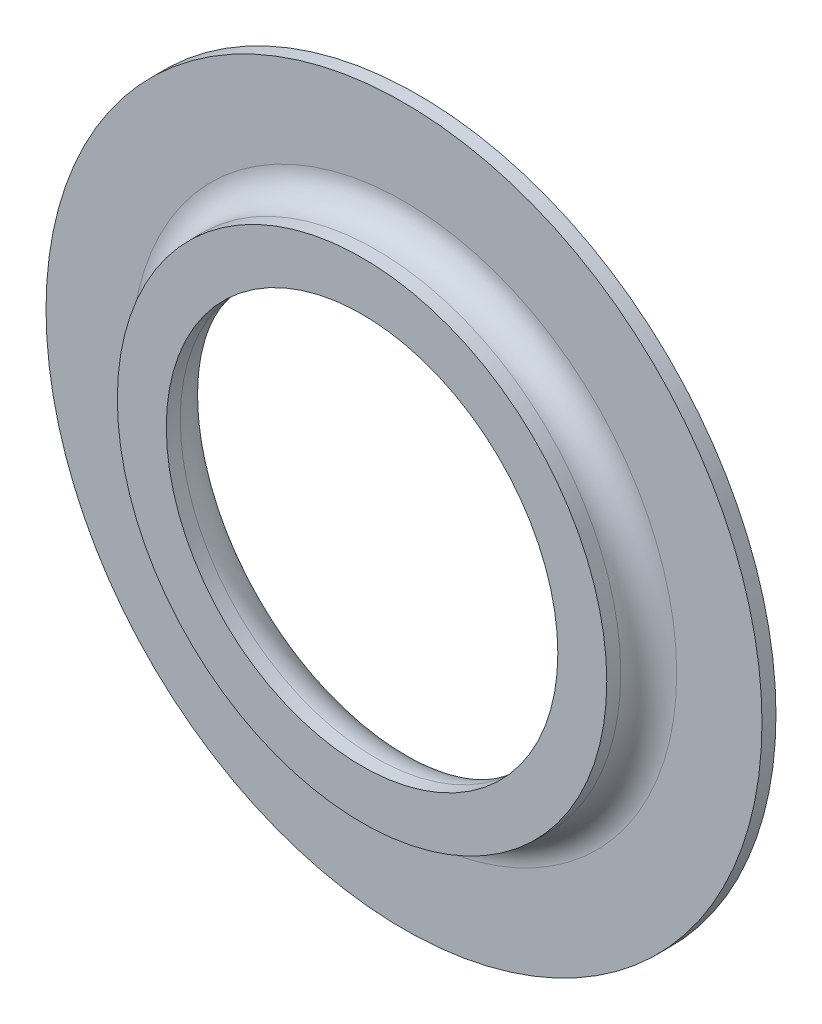
from build123d import *

# Parameters (mm, degrees)
SKETCH_1_R      = 25.6
SKETCH_1_R_2    = 14
EXTRUDE_1_DEPTH = 1
SKETCH_2_R      = 17.5
SKETCH_2_R_2    = 14
EXTRUDE_2_DEPTH = 3
FILLET_2_R      = 2
FILLET_3_R      = 3


with BuildPart() as part:
    # 草图1 → 凸台-拉伸1 (new body)
    with BuildSketch(Plane.XY):
        Circle(SKETCH_1_R)
        Circle(SKETCH_1_R_2, mode=Mode.SUBTRACT)
    extrude(amount=EXTRUDE_1_DEPTH)

    # 草图2 → 凸台-拉伸2 (add)
    with BuildSketch(Plane.XY.offset(1)):
        Circle(SKETCH_2_R)
        Circle(SKETCH_2_R_2, mode=Mode.SUBTRACT)
    extrude(amount=EXTRUDE_2_DEPTH)

    # 圆角2
    fillet_2_edges = [part.edges().sort_by_distance(p)[0] for p in [
        (-17.5, 0, 1),
    ]]
    fillet(fillet_2_edges, radius=FILLET_2_R)

    # 圆角3
    fillet_3_edges = [part.edges().sort_by_distance(p)[0] for p in [
        (-14, 0, 0),
    ]]
    fillet(fillet_3_edges, radius=FILLET_3_R)


solid = part.part
